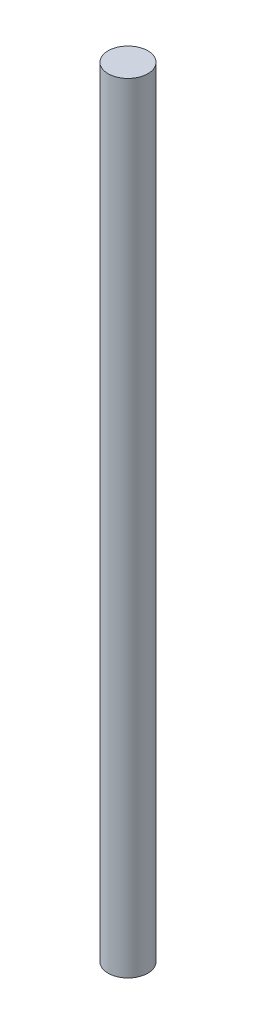
from build123d import *

# Parameters (mm, degrees)
SKETCH1_R                = 2.5
BOSS_EXTRUDE1_DEPTH      = 28
BOSS_EXTRUDE1_DEPTH_BACK = 70


with BuildPart() as part:
    # Sketch1 → Boss-Extrude1 (new body, two sides)
    with BuildSketch(Plane(origin=(0, 0, 0), x_dir=(1, 0, 0), z_dir=(0, 1, 0))) as boss_extrude1_sk:
        Circle(SKETCH1_R)
    extrude(amount=BOSS_EXTRUDE1_DEPTH)
    extrude(boss_extrude1_sk.sketch, amount=-BOSS_EXTRUDE1_DEPTH_BACK)


solid = part.part
